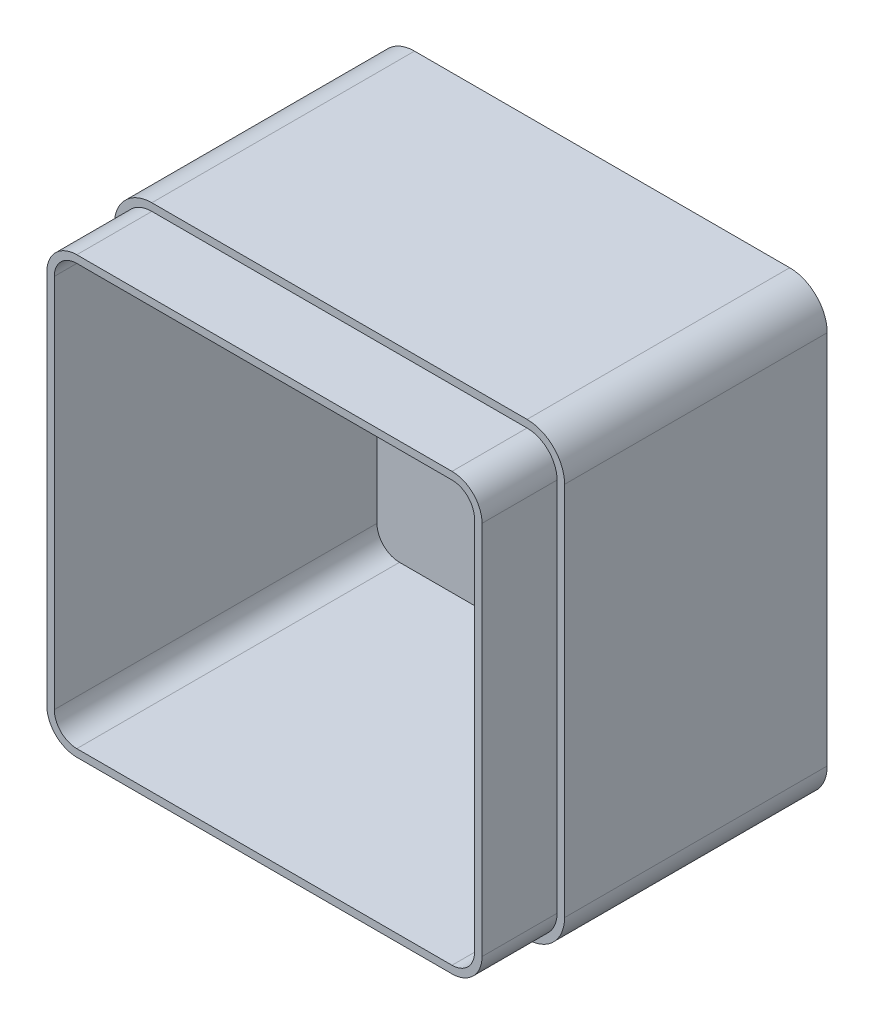
from build123d import *

# Parameters (mm, degrees)
SKETCH1_W           = 1200
SKETCH1_H           = 1200
BOSS_EXTRUDE1_DEPTH = 900
FILLET1_R           = 100
SHELL1_T            = -40
CUT_EXTRUDE2_DEPTH  = 200
SCALE3_SCALE        = 0.1


with BuildPart() as part:
    # Sketch1 → Boss-Extrude1 (new body)
    with BuildSketch(Plane.XY):
        with Locations((600, 600)):
            Rectangle(SKETCH1_W, SKETCH1_H)
    extrude(amount=BOSS_EXTRUDE1_DEPTH)

    # Fillet1
    fillet1_edges = [part.edges().sort_by_distance(p)[0] for p in [
        (0, 1200, 450),
        (1200, 1200, 450),
        (1200, 0, 450),
        (0, 0, 450),
    ]]
    fillet(fillet1_edges, radius=FILLET1_R)

    # Shell1
    shell1_openings = [part.faces().sort_by_distance(p)[0] for p in [
        (600, 600, 900),
    ]]
    offset(amount=SHELL1_T, openings=shell1_openings, kind=Kind.INTERSECTION)

    # Sketch4 → Cut-Extrude2 (cut)
    with BuildSketch(Plane.XY.offset(900)):
        with BuildLine():
            Line((100, 0), (1100, 0))
            ThreePointArc((1100, 0), (1170.710678119, 29.289321881), (1200, 100))
            Line((1200, 100), (1200, 1100))
            ThreePointArc((1200, 1100), (1170.710678119, 1170.710678119), (1100, 1200))
            Line((1100, 1200), (100, 1200))
            ThreePointArc((100, 1200), (29.289321881, 1170.710678119), (0, 1100))
            Line((0, 1100), (0, 100))
            ThreePointArc((0, 100), (29.289321881, 29.289321881), (100, 0))
        make_face()
        with BuildLine():
            Line((100, 20), (1100, 20))
            ThreePointArc((1100, 20), (1156.568542495, 43.431457505), (1180, 100))
            Line((1180, 100), (1180, 1100))
            ThreePointArc((1180, 1100), (1156.568542495, 1156.568542495), (1100, 1180))
            Line((1100, 1180), (100, 1180))
            ThreePointArc((100, 1180), (43.431457505, 1156.568542495), (20, 1100))
            Line((20, 1100), (20, 100))
            ThreePointArc((20, 100), (43.431457505, 43.431457505), (100, 20))
        make_face(mode=Mode.SUBTRACT)
    extrude(amount=-CUT_EXTRUDE2_DEPTH, mode=Mode.SUBTRACT)


with BuildPart() as part_1:
    # Scale3: scaled about (0, 0, 0)
    add(part.part.scale(SCALE3_SCALE))


solid = part_1.part
